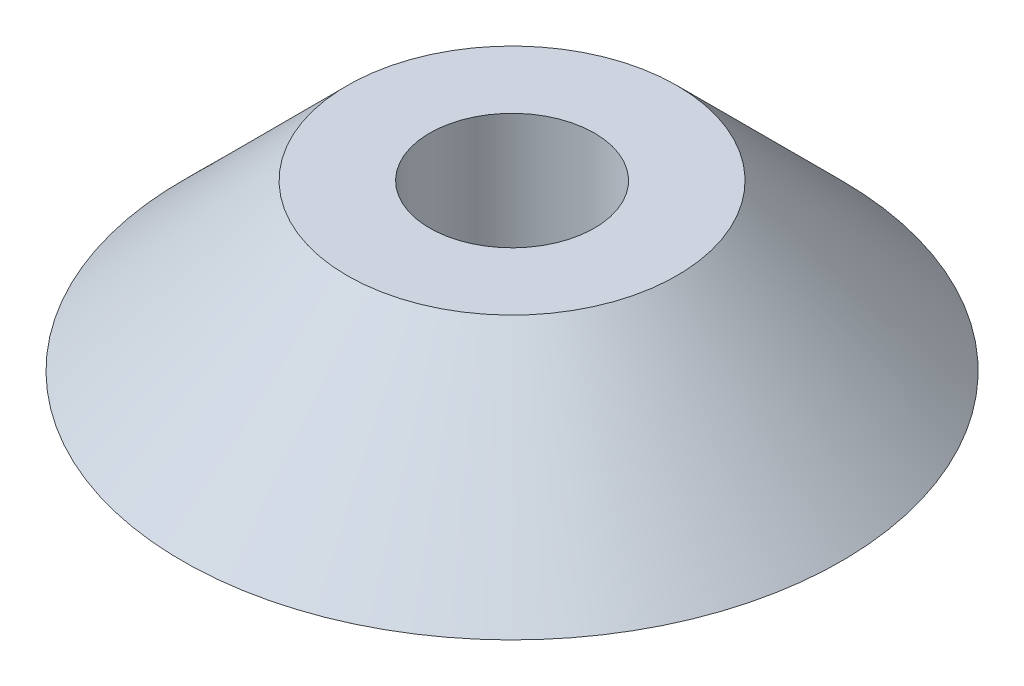
from build123d import *


with BuildPart() as part:
    # Sketch1 → Revolve1 (revolve)
    with BuildSketch(Plane.XY):
        Polygon((6.35, 0), (25.4, 0), (12.7, 12.7), (6.35, 12.7), align=None)
    revolve(axis=Axis((0, -1000.69375591, 0), (0, 1, 0)))


solid = part.part
